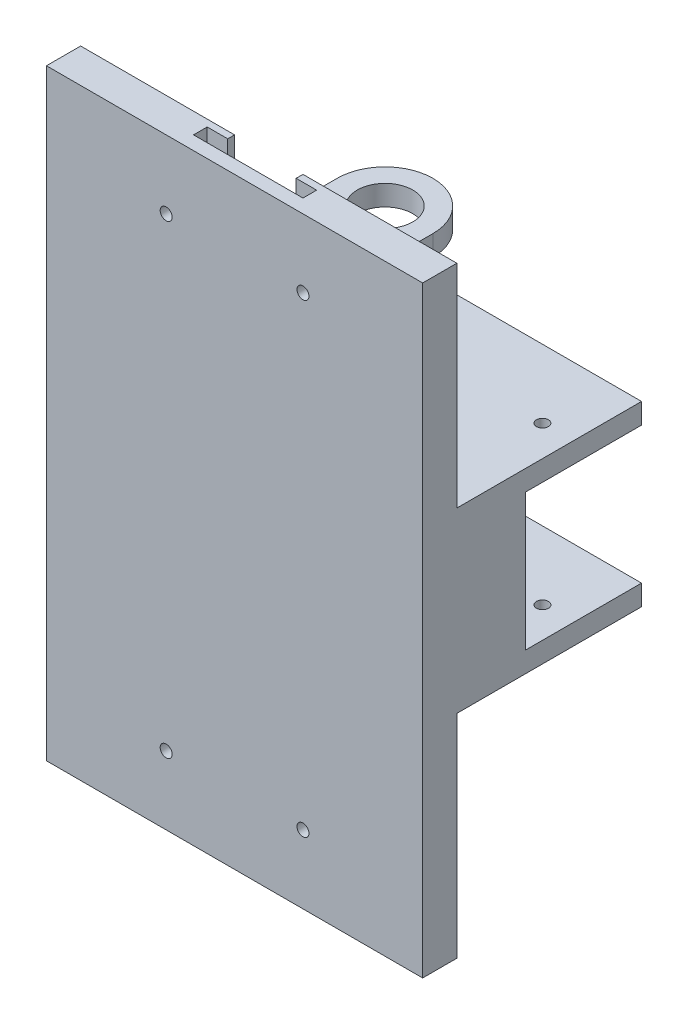
from build123d import *

# Parameters (mm, degrees)
SKETCH1_W                = 55
SKETCH1_H                = 32
SKETCH1_R                = 0.875
SKETCH1_R_2              = 6.5
BOSS_EXTRUDE1_DEPTH      = 3
BOSS_EXTRUDE2_START      = 3
SKETCH1_4_W              = 55
SKETCH1_4_H              = 5
BOSS_EXTRUDE2_DEPTH      = 13
BOSS_EXTRUDE3_START      = 16
BOSS_EXTRUDE3_DEPTH      = 3
BOSS_EXTRUDE4_START      = 19
BOSS_EXTRUDE4_DEPTH      = 15
SKETCH1_7_W              = 55
SKETCH1_7_H              = 5
BOSS_EXTRUDE5_DEPTH      = 10
SKETCH2_R                = 0.875
CUT_EXTRUDE1_DEPTH       = 52.393092921
CHAMFER1_SIZE            = 5
CHAMFER1_OF_MIRROR4_SIZE = 5
SKETCH3_W                = 5
SKETCH3_H                = 10
BOSS_EXTRUDE6_DEPTH      = 23


with BuildPart() as part:
    # Sketch1 → Boss-Extrude1 (new body)
    with BuildSketch(Plane(origin=(0, 0, 0), x_dir=(1, 0, 0), z_dir=(0, 1, 0))):
        with Locations((0, -6)):
            Rectangle(SKETCH1_W, SKETCH1_H)
        with Locations(Location((-23.0125, 0, 0), (0, 0, 270))):
            Circle(SKETCH1_R, mode=Mode.SUBTRACT)
        with Locations(Location((23.0125, 0, 0), (0, 0, 270))):
            Circle(SKETCH1_R, mode=Mode.SUBTRACT)
        with Locations(Location((0, 0, 0), (0, 0, 270))):
            Circle(SKETCH1_R_2, mode=Mode.SUBTRACT)
    boss_extrude1 = extrude(amount=BOSS_EXTRUDE1_DEPTH)

    # Sketch1_4 → Boss-Extrude2 (add)
    with BuildSketch(Plane(origin=(0, 0, 0), x_dir=(1, 0, 0), z_dir=(0, 1, 0)).offset(BOSS_EXTRUDE2_START)):
        with Locations((0, -19.5)):
            Rectangle(SKETCH1_4_W, SKETCH1_4_H)
    boss_extrude2 = extrude(amount=BOSS_EXTRUDE2_DEPTH)

    # Sketch1_5 → Boss-Extrude3 (add)
    with BuildSketch(Plane(origin=(0, 0, 0), x_dir=(1, 0, 0), z_dir=(0, 1, 0)).offset(BOSS_EXTRUDE3_START)):
        with BuildLine():
            Line((7, -17), (7, 0))
            Line((7, 0), (6.5, 0))
            ThreePointArc((6.5, 0), (0, -6.5), (-6.5, 0))
            Line((-6.5, 0), (-7, 0))
            Line((-7, 0), (-7, -17))
            Line((-7, -17), (-5, -17))
            Line((-5, -17), (5, -17))
            Line((5, -17), (7, -17))
        make_face()
        with BuildLine():
            ThreePointArc((-6.5, 0), (0, -6.5), (6.5, 0))
            Line((6.5, 0), (4.05, 0))
            ThreePointArc((4.05, 0), (0, -4.05), (-4.05, 0))
            Line((-4.05, 0), (-6.5, 0))
        make_face()
        with BuildLine():
            Line((4.05, 0), (6.5, 0))
            ThreePointArc((6.5, 0), (0, 6.5), (-6.5, 0))
            Line((-6.5, 0), (-4.05, 0))
            ThreePointArc((-4.05, 0), (0, 4.05), (4.05, 0))
        make_face()
        with BuildLine():
            Line((6.5, 0), (7, 0))
            ThreePointArc((7, 0), (0, 7), (-7, 0))
            Line((-7, 0), (-6.5, 0))
            ThreePointArc((-6.5, 0), (0, 6.5), (6.5, 0))
        make_face()
        Polygon((27.5, -17), (7, -17), (5, -17), (5, -18), (8, -18), (8, -20), (-8, -20), (-8, -18), (-5, -18), (-5, -17), (-7, -17), (-27.5, -17), (-27.5, -22), (27.5, -22), align=None)
        Polygon((5, -18), (5, -17), (-5, -17), (-5, -18), (-8, -18), (-8, -20), (8, -20), (8, -18), align=None)
    boss_extrude3 = extrude(amount=BOSS_EXTRUDE3_DEPTH)

    # Sketch1_6 → Boss-Extrude4 (add)
    with BuildSketch(Plane(origin=(0, 0, 0), x_dir=(1, 0, 0), z_dir=(0, 1, 0)).offset(BOSS_EXTRUDE4_START)):
        Polygon((-7, -17), (-27.5, -17), (-27.5, -22), (27.5, -22), (27.5, -17), (7, -17), (5, -17), (5, -18), (8, -18), (8, -20), (-8, -20), (-8, -18), (-5, -18), (-5, -17), align=None)
    boss_extrude4 = extrude(amount=BOSS_EXTRUDE4_DEPTH)

    # Sketch1_7 → Boss-Extrude5 (add)
    with BuildSketch(Plane(origin=(0, 0, 0), x_dir=(1, 0, 0), z_dir=(0, 1, 0))):
        with Locations((0, -19.5)):
            Rectangle(SKETCH1_7_W, SKETCH1_7_H)
    boss_extrude5 = extrude(amount=-BOSS_EXTRUDE5_DEPTH)

    # Sketch2 → Cut-Extrude1 (cut, through all)
    with BuildSketch(Plane(origin=(0, 0, 17), x_dir=(-1, 0, 0), z_dir=(0, 0, -1))):
        with Locations((-10, 24)):
            Circle(SKETCH2_R)
        with Locations((10, 24)):
            Circle(SKETCH2_R)
    cut_extrude1 = extrude(amount=-CUT_EXTRUDE1_DEPTH, mode=Mode.SUBTRACT)

    # Chamfer1
    chamfer1_edges = [part.edges().sort_by_distance(p)[0] for p in [
        (7, 17.5, 17),
        (-7, 17.5, 17),
    ]]
    chamfer(chamfer1_edges, length=CHAMFER1_SIZE)

    # Mirror4: Boss-Extrude1, Boss-Extrude2, Boss-Extrude3, Boss-Extrude4, Boss-Extrude5, Cut-Extrude1 across plane
    add(boss_extrude1.mirror(Plane(origin=(0, -10, 0), x_dir=(0, 0, 1), z_dir=(0, -1, 0))))
    add(boss_extrude2.mirror(Plane(origin=(0, -10, 0), x_dir=(0, 0, 1), z_dir=(0, -1, 0))))
    add(boss_extrude3.mirror(Plane(origin=(0, -10, 0), x_dir=(0, 0, 1), z_dir=(0, -1, 0))))
    add(boss_extrude4.mirror(Plane(origin=(0, -10, 0), x_dir=(0, 0, 1), z_dir=(0, -1, 0))))
    add(boss_extrude5.mirror(Plane(origin=(0, -10, 0), x_dir=(0, 0, 1), z_dir=(0, -1, 0))))
    add(cut_extrude1.mirror(Plane(origin=(0, -10, 0), x_dir=(0, 0, 1), z_dir=(0, -1, 0))), mode=Mode.SUBTRACT)

    # Chamfer1 of Mirror4
    chamfer1_of_mirror4_edges = [part.edges().sort_by_distance(p)[0] for p in [
        (7, -37.5, 17),
        (-7, -37.5, 17),
    ]]
    chamfer(chamfer1_of_mirror4_edges, length=CHAMFER1_OF_MIRROR4_SIZE)

    # Sketch3 → Boss-Extrude6 (add)
    with BuildSketch(Plane.XZ.offset(23)):
        with Locations((-25, 12)):
            Rectangle(SKETCH3_W, SKETCH3_H)
        with Locations((25, 12)):
            Rectangle(SKETCH3_W, SKETCH3_H)
    extrude(amount=-BOSS_EXTRUDE6_DEPTH)


solid = part.part
